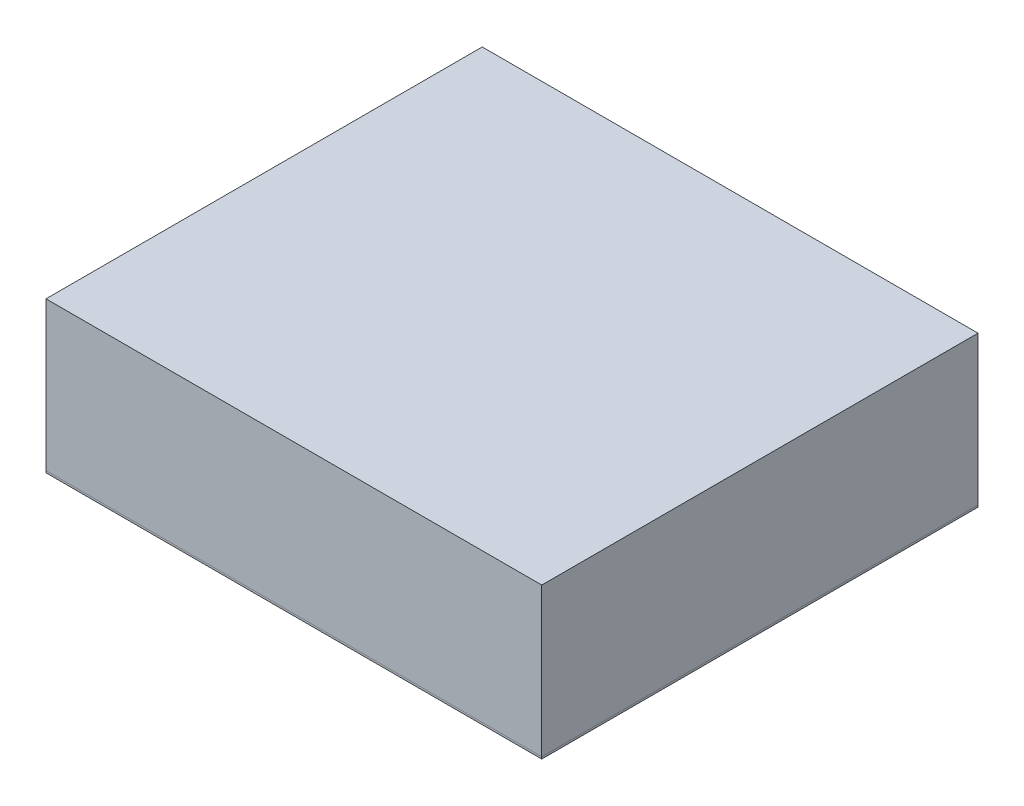
from build123d import *

# Parameters (mm, degrees)
SKETCH3_W           = 31.75
SKETCH3_H           = 9.525
BOSS_EXTRUDE1_DEPTH = 13.97
SKETCH4_W           = 31.75
SKETCH4_H           = 27.94
BOSS_EXTRUDE2_DEPTH = 0.127


with BuildPart() as part:
    # Sketch3 → Boss-Extrude1 (new, symmetric)
    with BuildSketch(Plane.XY):
        Rectangle(SKETCH3_W, SKETCH3_H)
    extrude(amount=BOSS_EXTRUDE1_DEPTH, both=True)


with BuildPart() as body_2:
    # Sketch4 → Boss-Extrude2 (new body)
    with BuildSketch(Plane.XZ.offset(4.7625)):
        Rectangle(SKETCH4_W, SKETCH4_H)
    extrude(amount=BOSS_EXTRUDE2_DEPTH)


solid = Compound([part.part, body_2.part])
